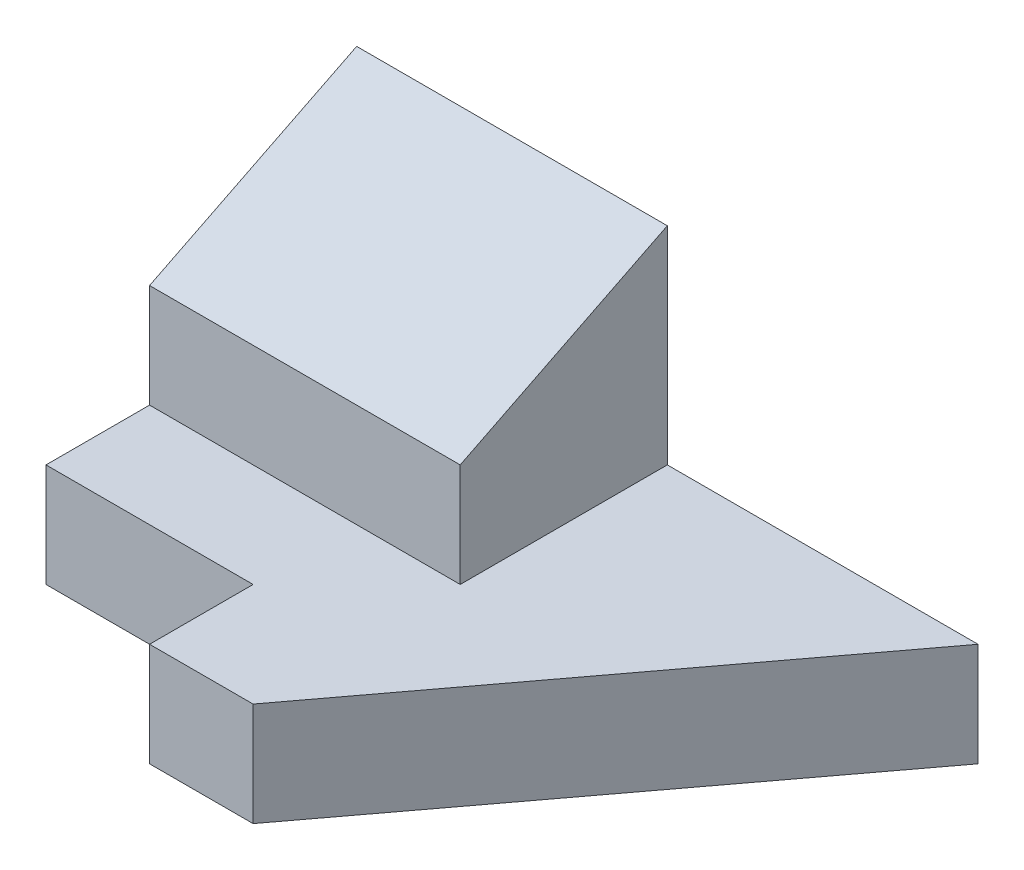
from build123d import *

# Parameters (mm, degrees)
BOSS_EXTRUDE1_DEPTH = 10
SKETCH5_W           = 20
SKETCH5_H           = 10
BOSS_EXTRUDE4_DEPTH = 30
BOSS_EXTRUDE5_DEPTH = 30


with BuildPart() as part:
    # Sketch1 → Boss-Extrude1 (new body)
    with BuildSketch(Plane(origin=(0, 0, 0), x_dir=(1, 0, 0), z_dir=(0, 1, 0))):
        Polygon((0, 0), (20, 0), (20, -10), (30, -10), (60, 30), (0, 30), align=None)
    extrude(amount=BOSS_EXTRUDE1_DEPTH)

    # Sketch5 → Boss-Extrude4 (add)
    with BuildSketch(Plane.ZY):
        with Locations((-20, 15)):
            Rectangle(SKETCH5_W, SKETCH5_H)
    extrude(amount=-BOSS_EXTRUDE4_DEPTH)

    # Sketch7 → Boss-Extrude5 (add)
    with BuildSketch(Plane(origin=(0, 0, 0), x_dir=(0, 0, -1), z_dir=(1, 0, 0))):
        Polygon((30, 20), (30, 30), (10, 20), align=None)
    extrude(amount=BOSS_EXTRUDE5_DEPTH)


solid = part.part
